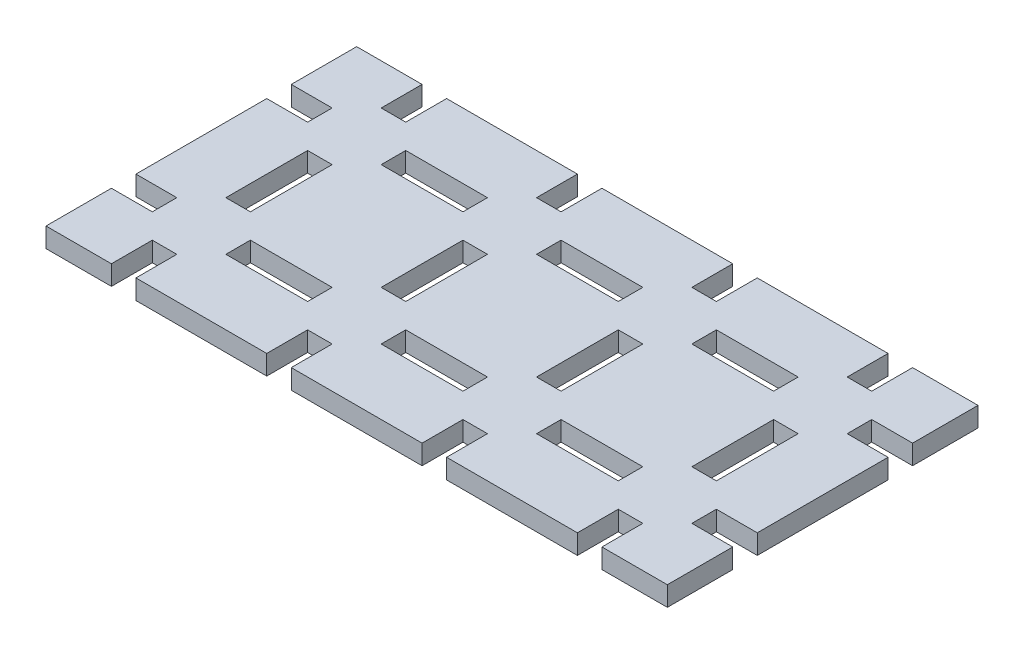
from build123d import *

# Parameters (mm, degrees)
ESQUISSE1_W             = 190
ESQUISSE1_H             = 95
BOSS_EXTRU_1_DEPTH      = 6
ESQUISSE9_W             = 12.5
ESQUISSE9_H             = 7.5
ESQUISSE9_W_2           = 25
ESQUISSE9_W_3           = 7.5
ESQUISSE9_H_2           = 12.5
ESQUISSE9_H_3           = 25
ENL_V_MAT_EXTRU_1_DEPTH = 6


with BuildPart() as part:
    # Esquisse1 → Boss.-Extru.1 (new body)
    with BuildSketch(Plane(origin=(0, 0, 0), x_dir=(1, 0, 0), z_dir=(0, 1, 0))):
        with Locations((-95, -47.5)):
            Rectangle(ESQUISSE1_W, ESQUISSE1_H)
    extrude(amount=BOSS_EXTRU_1_DEPTH)

    # Esquisse9 → Enlèv. mat.-Extru.1 (cut)
    with BuildSketch(Plane(origin=(0, 6, 0), x_dir=(1, 0, 0), z_dir=(0, 1, 0))):
        with Locations((-183.75, -23.75)):
            Rectangle(ESQUISSE9_W, ESQUISSE9_H)
        with Locations((-142.5, -23.75)):
            Rectangle(ESQUISSE9_W_2, ESQUISSE9_H)
        with Locations((-183.75, -71.25)):
            Rectangle(ESQUISSE9_W, ESQUISSE9_H)
        with Locations((-142.5, -71.25)):
            Rectangle(ESQUISSE9_W_2, ESQUISSE9_H)
        with Locations((-95, -71.25)):
            Rectangle(ESQUISSE9_W_2, ESQUISSE9_H)
        with Locations((-95, -23.75)):
            Rectangle(ESQUISSE9_W_2, ESQUISSE9_H)
        with Locations((-47.5, -23.75)):
            Rectangle(ESQUISSE9_W_2, ESQUISSE9_H)
        with Locations((-6.25, -23.75)):
            Rectangle(ESQUISSE9_W, ESQUISSE9_H)
        with Locations((-47.5, -71.25)):
            Rectangle(ESQUISSE9_W_2, ESQUISSE9_H)
        with Locations((-6.25, -71.25)):
            Rectangle(ESQUISSE9_W, ESQUISSE9_H)
        with Locations((-166.25, -88.75)):
            Rectangle(ESQUISSE9_W_3, ESQUISSE9_H_2)
        with Locations((-166.25, -47.5)):
            Rectangle(ESQUISSE9_W_3, ESQUISSE9_H_3)
        with Locations((-166.25, -6.25)):
            Rectangle(ESQUISSE9_W_3, ESQUISSE9_H_2)
        with Locations((-118.75, -88.75)):
            Rectangle(ESQUISSE9_W_3, ESQUISSE9_H_2)
        with Locations((-71.25, -88.75)):
            Rectangle(ESQUISSE9_W_3, ESQUISSE9_H_2)
        with Locations((-23.75, -88.75)):
            Rectangle(ESQUISSE9_W_3, ESQUISSE9_H_2)
        with Locations((-118.75, -47.5)):
            Rectangle(ESQUISSE9_W_3, ESQUISSE9_H_3)
        with Locations((-71.25, -47.5)):
            Rectangle(ESQUISSE9_W_3, ESQUISSE9_H_3)
        with Locations((-23.75, -47.5)):
            Rectangle(ESQUISSE9_W_3, ESQUISSE9_H_3)
        with Locations((-118.75, -6.25)):
            Rectangle(ESQUISSE9_W_3, ESQUISSE9_H_2)
        with Locations((-71.25, -6.25)):
            Rectangle(ESQUISSE9_W_3, ESQUISSE9_H_2)
        with Locations((-23.75, -6.25)):
            Rectangle(ESQUISSE9_W_3, ESQUISSE9_H_2)
    extrude(amount=-ENL_V_MAT_EXTRU_1_DEPTH, mode=Mode.SUBTRACT)


solid = part.part
